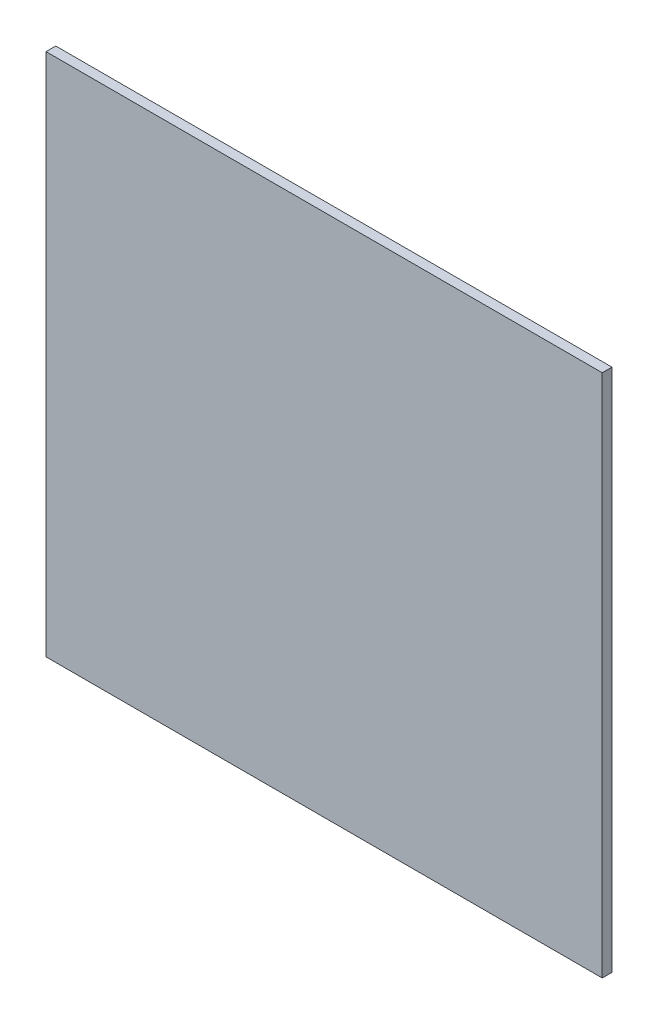
from build123d import *

# Parameters (mm, degrees)
SKETCH1_W           = 171.281919143
SKETCH1_H           = 161.411490283
BOSS_EXTRUDE1_DEPTH = 3


with BuildPart() as part:
    # Sketch1 → Boss-Extrude1 (new body)
    with BuildSketch(Plane.XY):
        with Locations((-29.010650556, -443.919731954)):
            Rectangle(SKETCH1_W, SKETCH1_H)
    extrude(amount=BOSS_EXTRUDE1_DEPTH)


solid = part.part
